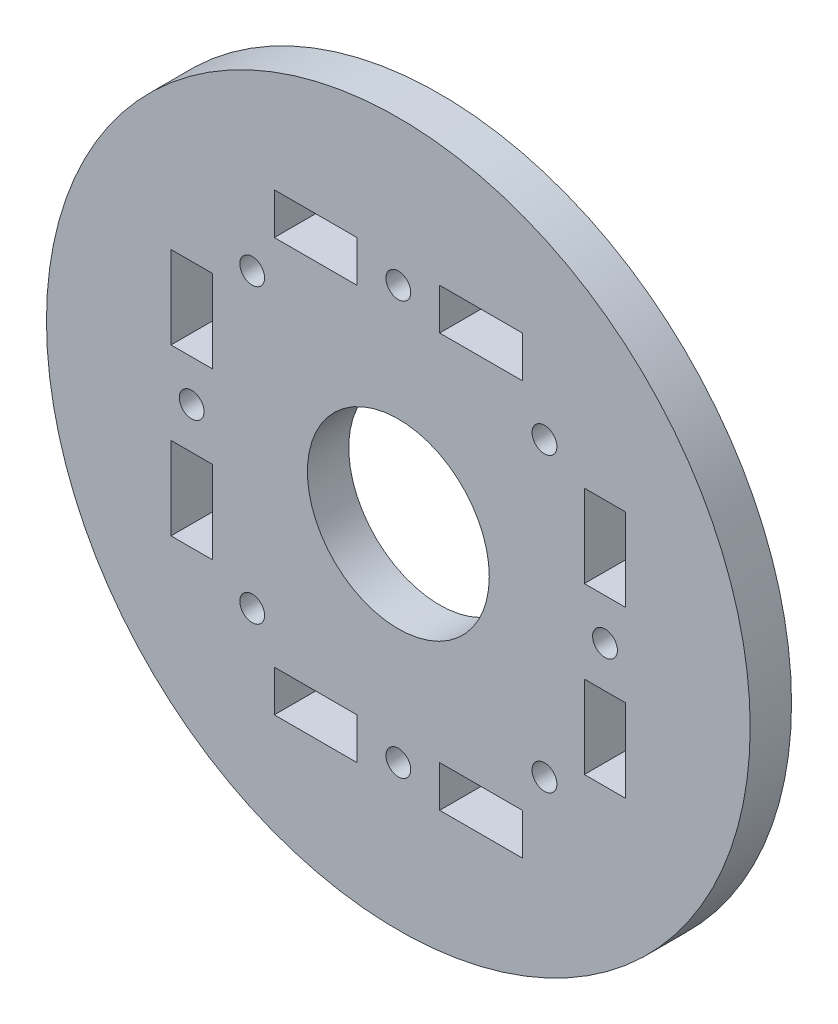
from build123d import *

# Parameters (mm, degrees)
SCHIZZO1_R                   = 42.562660939
ESTRUSIONE_ESTRUSIONE1_DEPTH = 5
SCHIZZO3_R                   = 11
TAGLIO_ESTRUSIONE2_DEPTH     = 6
SCHIZZO4_R                   = 1.5
SCHIZZO4_W                   = 5
SCHIZZO4_H                   = 10
SCHIZZO4_W_2                 = 10
SCHIZZO4_H_2                 = 5
TAGLIO_ESTRUSIONE3_DEPTH     = 6


with BuildPart() as part:
    # Schizzo1 → Estrusione-Estrusione1 (new body)
    with BuildSketch(Plane.XY):
        Circle(SCHIZZO1_R)
    extrude(amount=ESTRUSIONE_ESTRUSIONE1_DEPTH)

    # Schizzo3 → Taglio-Estrusione2 (cut, through all)
    with BuildSketch(Plane.XY):
        Circle(SCHIZZO3_R)
    extrude(amount=TAGLIO_ESTRUSIONE2_DEPTH, mode=Mode.SUBTRACT)

    # Schizzo4 → Taglio-Estrusione3 (cut, through all)
    with BuildSketch(Plane.XY):
        with Locations((0, 25)):
            Circle(SCHIZZO4_R)
        with Locations((17.67766953, 17.67766953)):
            Circle(SCHIZZO4_R)
        with Locations((25, 0)):
            Circle(SCHIZZO4_R)
        with Locations((17.67766953, -17.67766953)):
            Circle(SCHIZZO4_R)
        with Locations((0, -25)):
            Circle(SCHIZZO4_R)
        with Locations((-17.67766953, -17.67766953)):
            Circle(SCHIZZO4_R)
        with Locations((-25, 0)):
            Circle(SCHIZZO4_R)
        with Locations((-17.67766953, 17.67766953)):
            Circle(SCHIZZO4_R)
        with Locations((-25, -10)):
            Rectangle(SCHIZZO4_W, SCHIZZO4_H)
        with Locations((-25, 10)):
            Rectangle(SCHIZZO4_W, SCHIZZO4_H)
        with Locations((10, 25)):
            Rectangle(SCHIZZO4_W_2, SCHIZZO4_H_2)
        with Locations((-10, 25)):
            Rectangle(SCHIZZO4_W_2, SCHIZZO4_H_2)
        with Locations((25, -10)):
            Rectangle(SCHIZZO4_W, SCHIZZO4_H)
        with Locations((25, 10)):
            Rectangle(SCHIZZO4_W, SCHIZZO4_H)
        with Locations((-10, -25)):
            Rectangle(SCHIZZO4_W_2, SCHIZZO4_H_2)
        with Locations((10, -25)):
            Rectangle(SCHIZZO4_W_2, SCHIZZO4_H_2)
    extrude(amount=TAGLIO_ESTRUSIONE3_DEPTH, mode=Mode.SUBTRACT)


solid = part.part
